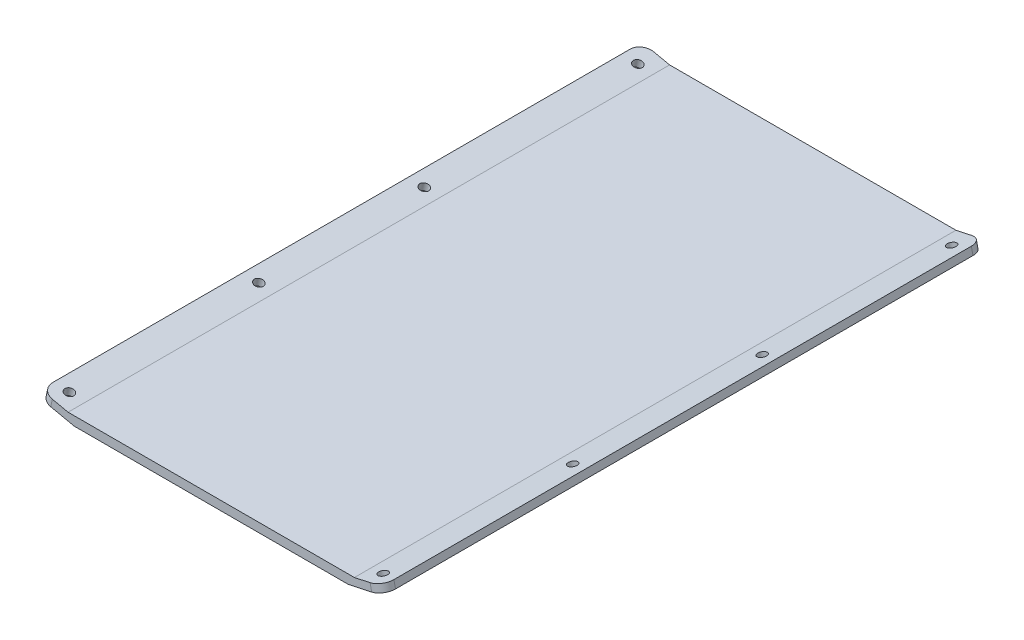
from build123d import *

# Parameters (mm, degrees)
BOSS_EXTRUDE1_DEPTH = 317.5
FILLET1_R           = 6.35
SKETCH3_R           = 2.38125
CUT_EXTRUDE1_DEPTH  = 317.5
SKETCH4_R           = 2.38125
CUT_EXTRUDE2_DEPTH  = 317.5
LPATTERN5_COUNT     = 4
LPATTERN5_PITCH     = 100.0125


with BuildPart() as part:
    # Sketch1 → Boss-Extrude1 (new body)
    with BuildSketch(Plane.XY):
        Polygon((75.565, 0), (-75.565, 0), (-90.065, 3.13), (-90.904357489, -0.758397314), (-72.355, -4.7625), (72.355, -4.7625), (90.904357489, -0.758397314), (90.065, 3.13), align=None)
    extrude(amount=BOSS_EXTRUDE1_DEPTH)

    # Fillet1
    fillet1_edges = [part.edges().sort_by_distance(p)[0] for p in [
        (-90.484678745, 1.185801343, 0),
        (90.484678745, 1.185801343, 317.5),
        (-90.484678745, 1.185801343, 317.5),
        (90.484678745, 1.185801343, 0),
    ]]
    fillet(fillet1_edges, radius=FILLET1_R)

    # Sketch3 → Cut-Extrude1 (cut)
    with BuildSketch(Plane(origin=(-3.364295287, -15.5853935, 0), x_dir=(0.977485615, -0.211002067, 0), z_dir=(0.211002067, 0.977485615, 0))):
        with Locations((-81.280689445, -9.525)):
            Circle(SKETCH3_R)
        with Locations((-81.280689445, -122.2375)):
            Circle(SKETCH3_R)
        with Locations((-81.280689445, -209.55)):
            Circle(SKETCH3_R)
        with Locations((-81.280689445, -309.5625)):
            Circle(SKETCH3_R)
    extrude(amount=-CUT_EXTRUDE1_DEPTH, mode=Mode.SUBTRACT)

    # Sketch4 → Cut-Extrude2 (cut)
    with BuildSketch(Plane(origin=(3.364295287, -15.5853935, 0), x_dir=(0.977485615, 0.211002067, 0), z_dir=(-0.211002067, 0.977485615, 0))):
        with Locations((81.280689445, -9.525)):
            Circle(SKETCH4_R)
    cut_extrude2 = extrude(amount=-CUT_EXTRUDE2_DEPTH, mode=Mode.SUBTRACT)

    # LPattern5: Cut-Extrude2 ×4
    with Locations(*[(0, 0, i * LPATTERN5_PITCH) for i in range(1, LPATTERN5_COUNT)]):
        add(cut_extrude2, mode=Mode.SUBTRACT)


solid = part.part
